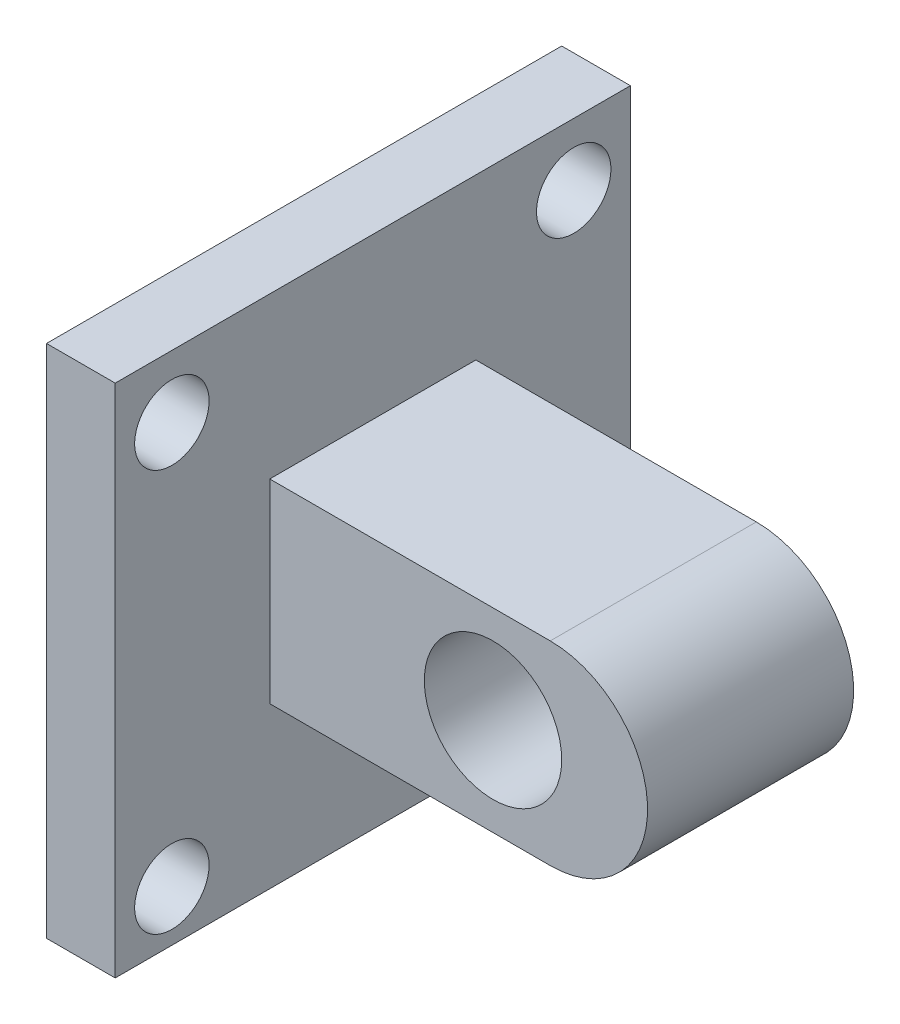
from build123d import *

# Parameters (mm, degrees)
DODANIE_WYCI_GNI_CIE3_DEPTH      = 18
DODANIE_WYCI_GNI_CIE3_DEPTH_BACK = 18
SZKIC1_R                         = 12
DODANIE_WYCI_GNI_CIE4_DEPTH      = 45
DODANIE_WYCI_GNI_CIE4_DEPTH_BACK = 45
SKETCH5_R                        = 6.5
CUT_EXTRUDE1_DEPTH               = 12


with BuildPart() as part:
    # Szkic1 → Dodanie-wyci_gni_cie3 (new, two sides: drawn at the far end of the back side and taken through both)
    with BuildSketch(Plane.XY.offset(-DODANIE_WYCI_GNI_CIE3_DEPTH_BACK)):
        with BuildLine():
            Line((-788.553538537, 574.11980128), (-837.553538537, 574.11980128))
            Line((-837.553538537, 574.11980128), (-837.553538537, 540.11980128))
            Line((-837.553538537, 540.11980128), (-788.553538537, 540.11980128))
            ThreePointArc((-788.553538537, 540.11980128), (-771.553538537, 557.11980128), (-788.553538537, 574.11980128))
        make_face()
        with Locations((-798.553538537, 557.11980128)):
            Circle(SZKIC1_R, mode=Mode.SUBTRACT)
    extrude(amount=DODANIE_WYCI_GNI_CIE3_DEPTH + DODANIE_WYCI_GNI_CIE3_DEPTH_BACK)

    # Szkic1_6 → Dodanie-wyci_gni_cie4 (add, two sides: drawn at the far end of the back side and taken through both)
    with BuildSketch(Plane.XY.offset(-DODANIE_WYCI_GNI_CIE4_DEPTH_BACK)):
        Polygon((-837.553538537, 602.11980128), (-849.553538537, 602.11980128), (-849.553538537, 512.11980128), (-837.553538537, 512.11980128), (-837.553538537, 540.11980128), (-837.553538537, 574.11980128), align=None)
    extrude(amount=DODANIE_WYCI_GNI_CIE4_DEPTH + DODANIE_WYCI_GNI_CIE4_DEPTH_BACK)

    # Sketch5 → Cut-Extrude1 (cut)
    with BuildSketch(Plane(origin=(-837.553538537, 0, 0), x_dir=(0, 0, -1), z_dir=(1, 0, 0))):
        with Locations((-35.100505063, 591.220306343)):
            Circle(SKETCH5_R)
        with Locations((35.100505063, 591.220306343)):
            Circle(SKETCH5_R)
        with Locations((35.100505063, 521.019296217)):
            Circle(SKETCH5_R)
        with Locations((-35.100505063, 521.019296217)):
            Circle(SKETCH5_R)
    extrude(amount=-CUT_EXTRUDE1_DEPTH, mode=Mode.SUBTRACT)


solid = part.part
